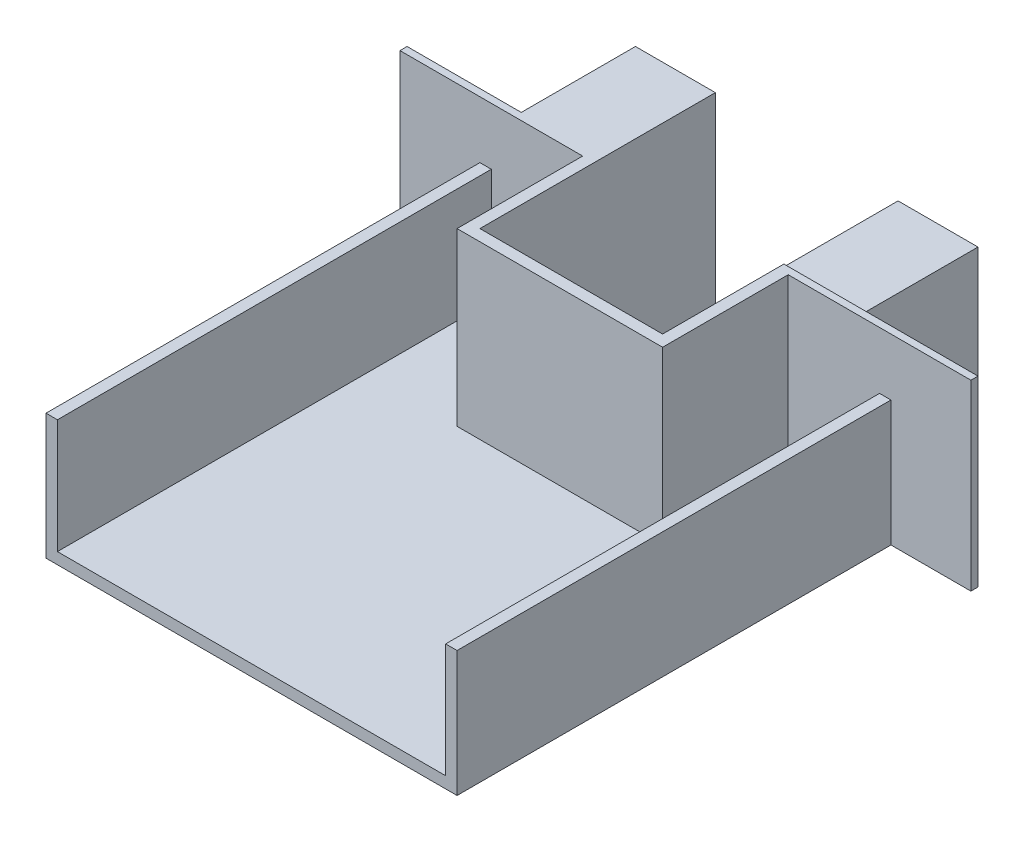
from build123d import *

# Parameters (mm, degrees)
SKETCH2_W           = 180
SKETCH2_H           = 190
BOSS_EXTRUDE3_DEPTH = 5
SKETCH4_W           = 5
SKETCH4_H           = 190
BOSS_EXTRUDE4_DEPTH = 50
SKETCH6_W           = 250
SKETCH6_H           = 3.1090482
BOSS_EXTRUDE6_DEPTH = 80
SKETCH7_W           = 35
SKETCH7_H           = 78.948410215
SKETCH7_H_2         = 80
BOSS_EXTRUDE7_DEPTH = 50
SKETCH8_W           = 80
SKETCH8_H           = 3.1090482
CUT_EXTRUDE1_DEPTH  = 123
SKETCH9_W           = 80
SKETCH9_H           = 50
CUT_EXTRUDE2_DEPTH  = 123
BOSS_EXTRUDE8_DEPTH = 75


with BuildPart() as part:
    # Sketch2 → Boss-Extrude3 (new body)
    with BuildSketch(Plane(origin=(0, 0, 0), x_dir=(1, 0, 0), z_dir=(0, 1, 0))):
        Rectangle(SKETCH2_W, SKETCH2_H)
    extrude(amount=BOSS_EXTRUDE3_DEPTH)

    # Sketch4 → Boss-Extrude4 (add)
    with BuildSketch(Plane(origin=(0, 5, 0), x_dir=(1, 0, 0), z_dir=(0, 1, 0))):
        with Locations((-87.5, 0)):
            Rectangle(SKETCH4_W, SKETCH4_H)
        with Locations((87.5, 0)):
            Rectangle(SKETCH4_W, SKETCH4_H)
    extrude(amount=BOSS_EXTRUDE4_DEPTH)

    # Sketch6 → Boss-Extrude6 (add)
    with BuildSketch(Plane(origin=(0, 0, 0), x_dir=(1, 0, 0), z_dir=(0, 1, 0))):
        with Locations((0, 96.5545241)):
            Rectangle(SKETCH6_W, SKETCH6_H)
    extrude(amount=BOSS_EXTRUDE6_DEPTH)

    # Sketch7 → Boss-Extrude7 (add)
    with BuildSketch(Plane(origin=(0, 0, -98.1090482), x_dir=(-1, 0, 0), z_dir=(0, 0, -1))):
        with Locations((-57.5, 39.474205108)):
            Rectangle(SKETCH7_W, SKETCH7_H)
        with Locations((57.5, 40)):
            Rectangle(SKETCH7_W, SKETCH7_H_2)
    extrude(amount=BOSS_EXTRUDE7_DEPTH)

    # Sketch8 → Cut-Extrude1 (cut)
    with BuildSketch(Plane(origin=(0, 80, 0), x_dir=(1, 0, 0), z_dir=(0, 1, 0))):
        with Locations((0, 96.5545241)):
            Rectangle(SKETCH8_W, SKETCH8_H)
    extrude(amount=-CUT_EXTRUDE1_DEPTH, mode=Mode.SUBTRACT)

    # Sketch9 → Cut-Extrude2 (cut)
    with BuildSketch(Plane(origin=(0, 5, 0), x_dir=(1, 0, 0), z_dir=(0, 1, 0))):
        with Locations((0, 70)):
            Rectangle(SKETCH9_W, SKETCH9_H)
    extrude(amount=-CUT_EXTRUDE2_DEPTH, mode=Mode.SUBTRACT)

    # Sketch10 → Boss-Extrude8 (add)
    with BuildSketch(Plane(origin=(0, 5, 0), x_dir=(1, 0, 0), z_dir=(0, 1, 0))):
        Polygon((-40, 95), (-40, 45), (40, 45), (40, 95), (45, 95), (45, 40), (-45, 40), (-45, 95), align=None)
    extrude(amount=BOSS_EXTRUDE8_DEPTH)


solid = part.part
